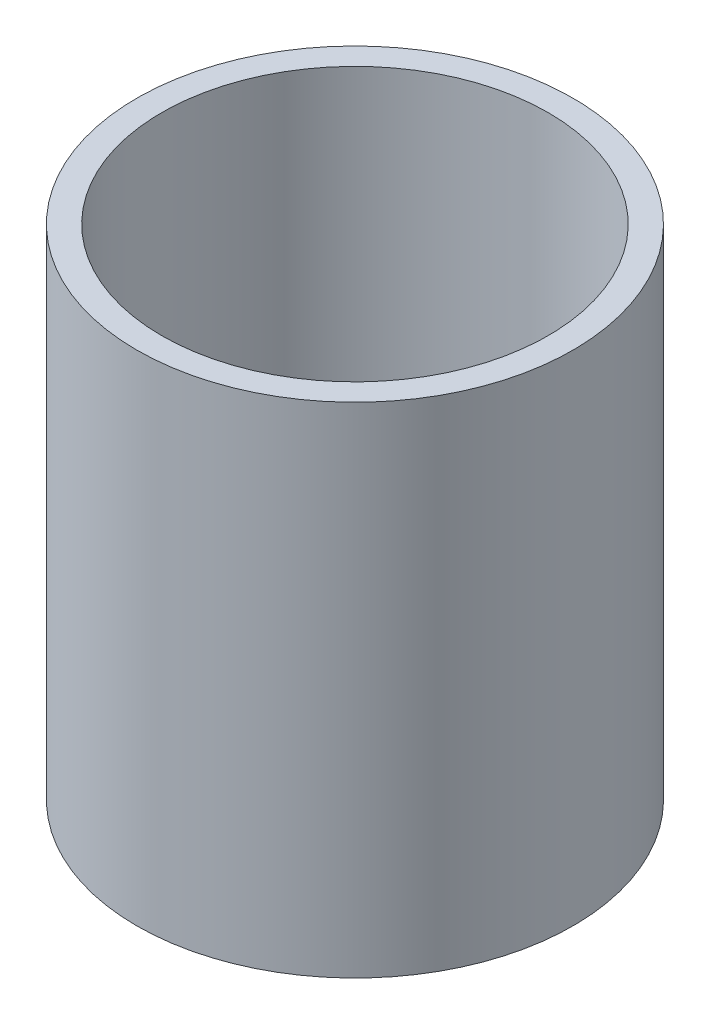
from build123d import *

# Parameters (mm, degrees)
SKETCH1_R           = 55.5625
SKETCH1_R_2         = 49.2125
BOSS_EXTRUDE1_DEPTH = 127


with BuildPart() as part:
    # Sketch1 → Boss-Extrude1 (new body)
    with BuildSketch(Plane(origin=(0, 0, 0), x_dir=(1, 0, 0), z_dir=(0, 1, 0))):
        Circle(SKETCH1_R)
        Circle(SKETCH1_R_2, mode=Mode.SUBTRACT)
    extrude(amount=BOSS_EXTRUDE1_DEPTH)


solid = part.part
